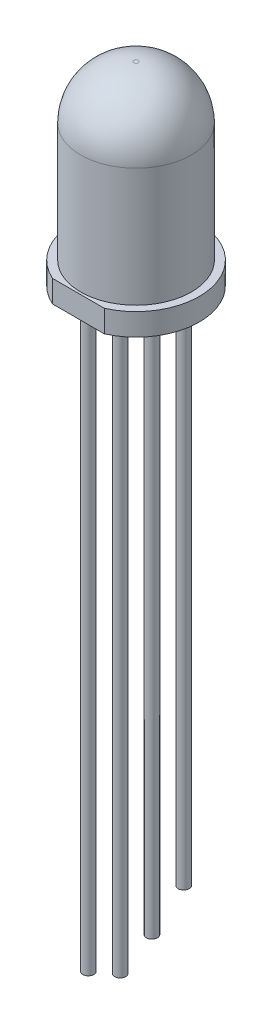
from build123d import *

# Parameters (mm, degrees)
CUT_EXTRUDE1_DEPTH  = 1
SKETCH3_R           = 0.25
BOSS_EXTRUDE1_DEPTH = 24.5
SKETCH4_R           = 0.25
BOSS_EXTRUDE2_DEPTH = 1.2
SKETCH5_R           = 0.25
BOSS_EXTRUDE3_DEPTH = 2


with BuildPart() as part:
    # Sketch1 → Revolve1 (revolve)
    with BuildSketch(Plane.XY):
        with BuildLine():
            Line((0, 0), (0, 8.75))
            Line((0, 8.75), (0.1, 8.75))
            ThreePointArc((0.1, 8.75), (1.797056275, 8.047056275), (2.5, 6.35))
            Line((2.5, 6.35), (2.5, 1))
            Line((2.5, 1), (2.85, 1))
            Line((2.85, 1), (2.85, 0))
            Line((2.85, 0), (0, 0))
        make_face()
    revolve(axis=Axis((0, 0, 0), (0, 1, 0)))

    # Sketch2 → Cut-Extrude1 (cut)
    with BuildSketch(Plane.XZ):
        with BuildLine():
            Line((-1.167261753, 2.6), (1.167261753, 2.6))
            ThreePointArc((1.167261753, 2.6), (0, 2.85), (-1.167261753, 2.6))
        make_face()
    extrude(amount=-CUT_EXTRUDE1_DEPTH, mode=Mode.SUBTRACT)

    # Sketch3 → Boss-Extrude1 (add)
    with BuildSketch(Plane.XZ):
        with Locations((0, -2.15)):
            Circle(SKETCH3_R)
        with Locations((0, 2.15)):
            Circle(SKETCH3_R)
        with Locations((0, -0.716666667)):
            Circle(SKETCH3_R)
        with Locations((0, 0.716666667)):
            Circle(SKETCH3_R)
    extrude(amount=BOSS_EXTRUDE1_DEPTH)

    # Sketch4 → Boss-Extrude2 (add)
    with BuildSketch(Plane.XZ.offset(24.5)):
        with Locations((0, 2.15)):
            Circle(SKETCH4_R)
        with Locations((0, -0.716666667)):
            Circle(SKETCH4_R)
    extrude(amount=BOSS_EXTRUDE2_DEPTH)

    # Sketch5 → Boss-Extrude3 (add)
    with BuildSketch(Plane.XZ.offset(24.5)):
        with Locations((0, 0.716666667)):
            Circle(SKETCH5_R)
    extrude(amount=BOSS_EXTRUDE3_DEPTH)


solid = part.part
